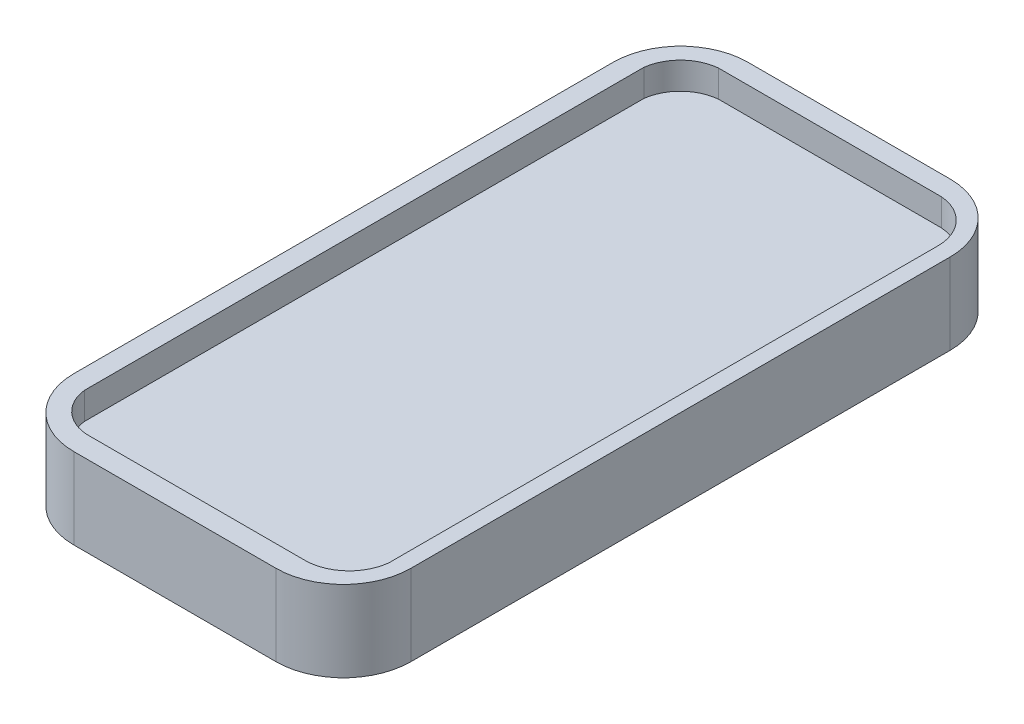
from build123d import *

# Parameters (mm, degrees)
CROQUIS2_W              = 500
CROQUIS2_H              = 1000
SALIENTE_EXTRUIR1_DEPTH = 120
REDONDEO3_R             = 100
CORTAR_EXTRUIR3_DEPTH   = 40


with BuildPart() as part:
    # Croquis2 → Saliente-Extruir1 (new body)
    with BuildSketch(Plane(origin=(0, 0, 0), x_dir=(1, 0, 0), z_dir=(0, 1, 0))):
        with Locations((242.219540343, 451.577872827)):
            Rectangle(CROQUIS2_W, CROQUIS2_H)
    extrude(amount=SALIENTE_EXTRUIR1_DEPTH)

    # Redondeo3
    redondeo3_edges = [part.edges().sort_by_distance(p)[0] for p in [
        (-7.780459657, 60, -951.577872827),
        (492.219540343, 60, -951.577872827),
        (492.219540343, 60, 48.422127173),
        (-7.780459657, 60, 48.422127173),
    ]]
    fillet(redondeo3_edges, radius=REDONDEO3_R)

    # Croquis6 → Cortar-Extruir3 (cut)
    with BuildSketch(Plane(origin=(0, 120, 0), x_dir=(1, 0, 0), z_dir=(0, 1, 0))):
        with BuildLine():
            Line((77.752240524, 922.288550945), (408.615788101, 922.288550945))
            ThreePointArc((408.615788101, 922.288550945), (451.385829489, 901.312824814), (468.879013747, 857.004292547))
            Line((468.879013747, 857.004292547), (468.879013747, 42.218165752))
            ThreePointArc((468.879013747, 42.218165752), (448.612113313, 1.380200922), (406.780484602, -16.747166896))
            Line((406.780484602, -16.747166896), (79.587544024, -16.747166896))
            ThreePointArc((79.587544024, -16.747166896), (40.695958229, 0.077623427), (21.508862224, 37.859687451))
            Line((21.508862224, 37.859687451), (21.508862224, 867.822814394))
            ThreePointArc((21.508862224, 867.822814394), (40.030080371, 904.969491914), (77.752240524, 922.288550945))
        make_face()
    extrude(amount=-CORTAR_EXTRUIR3_DEPTH, mode=Mode.SUBTRACT)


solid = part.part
